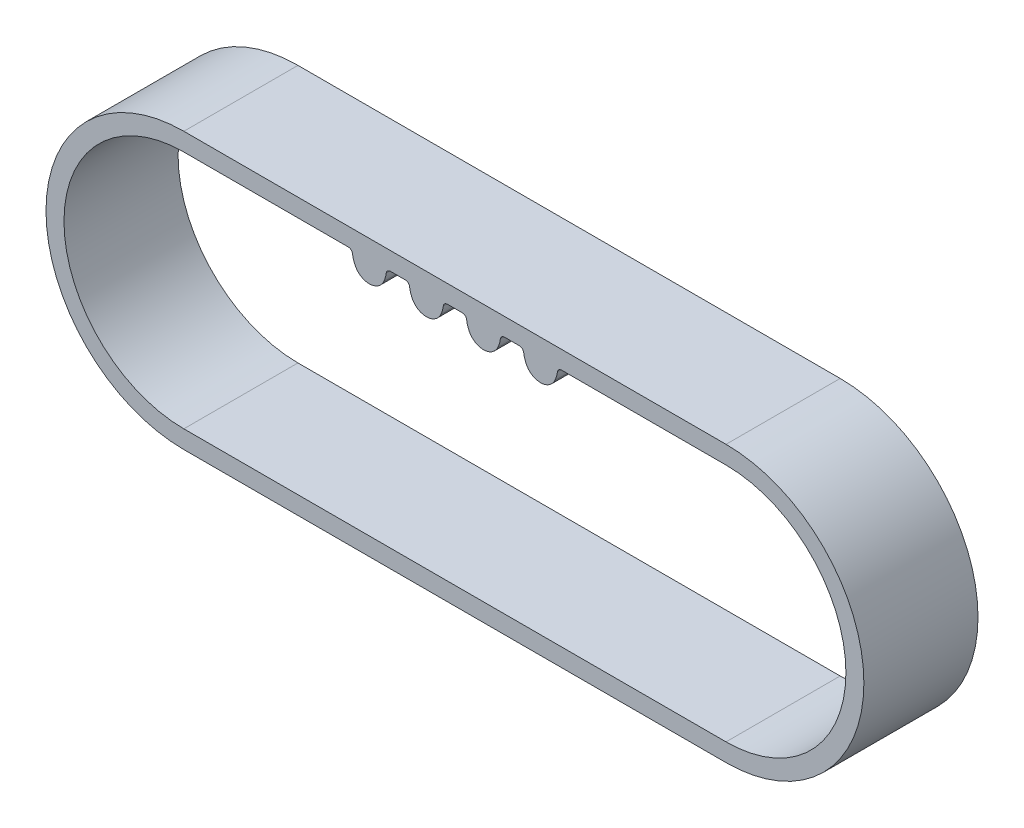
from build123d import *

# Parameters (mm, degrees)
BOSS_EXTRUDE1_DEPTH = 2
BOSS_EXTRUDE2_DEPTH = 2
LPATTERN1_COUNT     = 2
LPATTERN1_PITCH     = 4


with BuildPart() as part:
    # Sketch1 → Boss-Extrude1 (new body, symmetric)
    with BuildSketch(Plane.XY):
        with BuildLine():
            Line((0, 4.831), (19.004204728, 4.831))
            ThreePointArc((19.004204728, 4.831), (23.835204728, 0), (19.004204728, -4.831))
            Line((19.004204728, -4.831), (0, -4.831))
            ThreePointArc((0, -4.831), (-4.831, 0), (0, 4.831))
        make_face()
        with BuildLine():
            Line((0, 4.201), (19.004204728, 4.201))
            ThreePointArc((19.004204728, 4.201), (23.205204728, 0), (19.004204728, -4.201))
            Line((19.004204728, -4.201), (0, -4.201))
            ThreePointArc((0, -4.201), (-4.201, 0), (0, 4.201))
        make_face(mode=Mode.SUBTRACT)
    extrude(amount=BOSS_EXTRUDE1_DEPTH, both=True)

    # Sketch2 → Boss-Extrude2 (add, symmetric)
    with BuildSketch(Plane.XY):
        with BuildLine():
            Line((5.502102364, 4.831), (5.502102364, 4.201))
            Line((5.502102364, 4.201), (5.761926939, 4.201))
            ThreePointArc((5.761926939, 4.201), (5.86083401, 4.163771412), (5.910645473, 4.070565217))
            ThreePointArc((5.910645473, 4.070565217), (5.94449065, 3.912937846), (6.00322596, 3.762797753))
            ThreePointArc((6.00322596, 3.762797753), (6.502102364, 3.451), (7.000978769, 3.762797753))
            ThreePointArc((7.000978769, 3.762797753), (7.059714078, 3.912937846), (7.093559256, 4.070565217))
            ThreePointArc((7.093559256, 4.070565217), (7.143370718, 4.163771412), (7.242277789, 4.201))
            Line((7.242277789, 4.201), (7.761926939, 4.201))
            ThreePointArc((7.761926939, 4.201), (7.86083401, 4.163771412), (7.910645473, 4.070565217))
            ThreePointArc((7.910645473, 4.070565217), (7.94449065, 3.912937846), (8.00322596, 3.762797753))
            ThreePointArc((8.00322596, 3.762797753), (8.502102364, 3.451), (9.000978769, 3.762797753))
            ThreePointArc((9.000978769, 3.762797753), (9.059714078, 3.912937846), (9.093559256, 4.070565217))
            ThreePointArc((9.093559256, 4.070565217), (9.143370718, 4.163771412), (9.242277789, 4.201))
            Line((9.242277789, 4.201), (9.502102364, 4.201))
            Line((9.502102364, 4.201), (9.502102364, 4.831))
            Line((9.502102364, 4.831), (5.502102364, 4.831))
        make_face()
    boss_extrude2 = extrude(amount=BOSS_EXTRUDE2_DEPTH, both=True)

    # LPattern1: Boss-Extrude2 ×2
    with Locations(*[(i * LPATTERN1_PITCH, 0, 0) for i in range(1, LPATTERN1_COUNT)]):
        add(boss_extrude2)


solid = part.part
